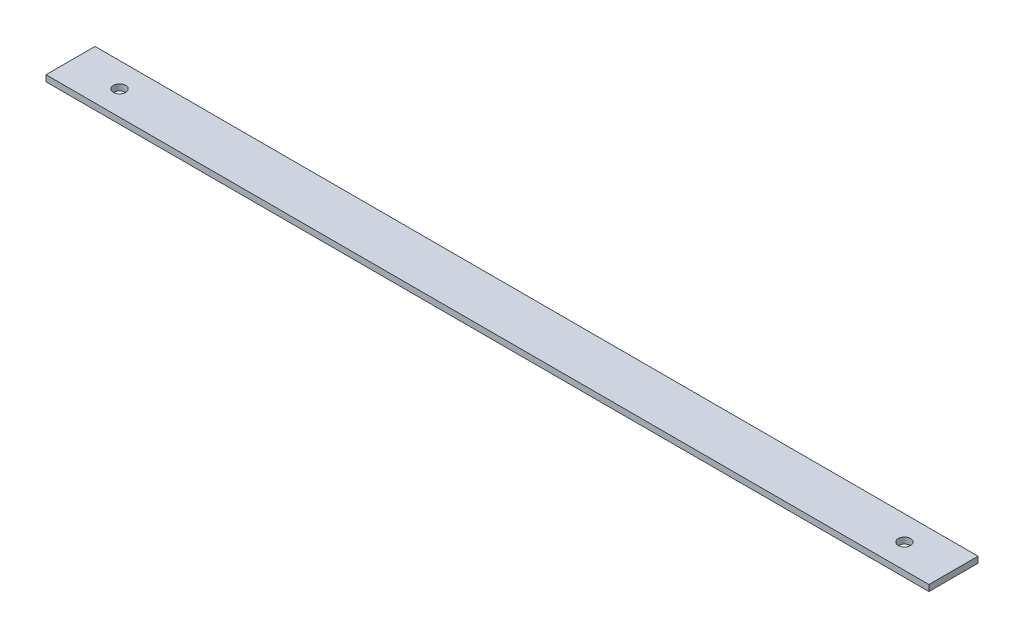
from build123d import *

# Parameters (mm, degrees)
SKETCH1_W           = 457.2
SKETCH1_H           = 25.4
BOSS_EXTRUDE1_DEPTH = 3.175
SKETCH2_R           = 3.175
CUT_EXTRUDE1_DEPTH  = 4.175


with BuildPart() as part:
    # Sketch1 → Boss-Extrude1 (new body)
    with BuildSketch(Plane(origin=(0, 0, 0), x_dir=(1, 0, 0), z_dir=(0, 1, 0))):
        with Locations((228.6, 12.7)):
            Rectangle(SKETCH1_W, SKETCH1_H)
    extrude(amount=BOSS_EXTRUDE1_DEPTH)

    # Sketch2 → Cut-Extrude1 (cut, through all)
    with BuildSketch(Plane(origin=(0, 3.175, 0), x_dir=(1, 0, 0), z_dir=(0, 1, 0))):
        with Locations((431.8, 12.7)):
            Circle(SKETCH2_R)
        with Locations((25.4, 12.7)):
            Circle(SKETCH2_R)
    extrude(amount=-CUT_EXTRUDE1_DEPTH, mode=Mode.SUBTRACT)


solid = part.part
